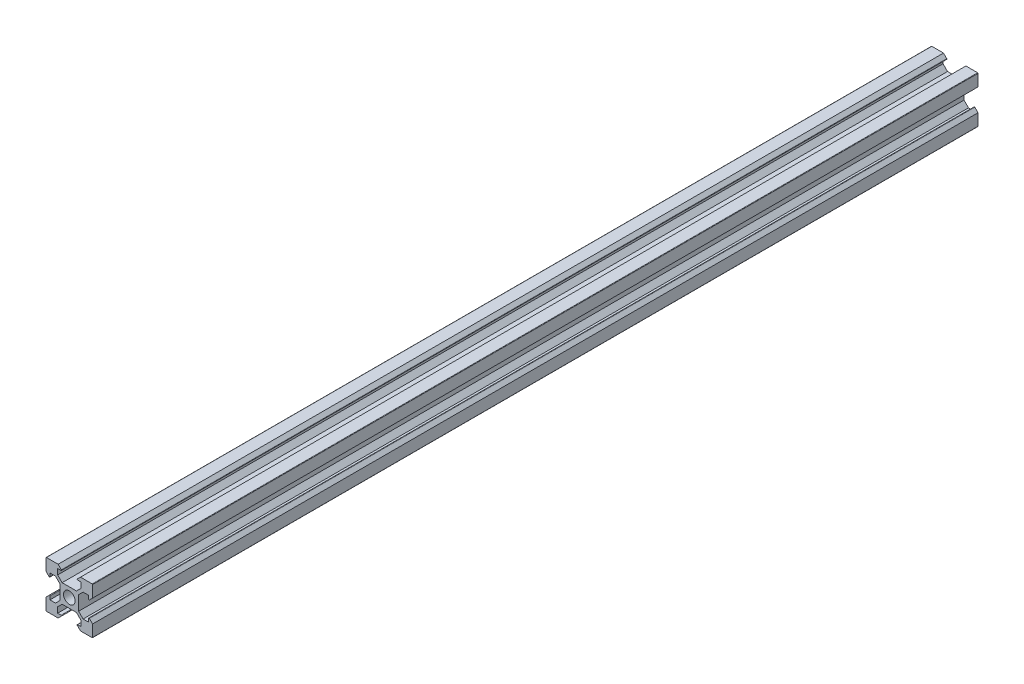
from build123d import *

# Parameters (mm, degrees)
SKETCH1_R           = 2.5
BOSS_EXTRUDE4_DEPTH = 380


with BuildPart() as part:
    # Sketch1 → Boss-Extrude4 (new body)
    with BuildSketch(Plane.XY):
        with BuildLine():
            Line((-10, 9.810918806), (-10, 4.8))
            Line((-10, 4.8), (-8.622781789, 3.422781789))
            ThreePointArc((-8.622781789, 3.422781789), (-8.416722954, 3.381794139), (-8.3, 3.556482384))
            Line((-8.3, 3.556482384), (-8.3, 5))
            Line((-8.3, 5), (-5.919238816, 5))
            Line((-5.919238816, 5), (-4, 3.080761184))
            Line((-4, 3.080761184), (-4, -3.080761184))
            Line((-4, -3.080761184), (-5.919238816, -5))
            Line((-5.919238816, -5), (-8.3, -5))
            Line((-8.3, -5), (-8.3, -3.556482384))
            ThreePointArc((-8.3, -3.556482384), (-8.416722954, -3.381794139), (-8.622781789, -3.422781789))
            Line((-8.622781789, -3.422781789), (-10, -4.8))
            Line((-10, -4.8), (-10, -9.810918806))
            ThreePointArc((-10, -9.810918806), (-9.9446194, -9.9446194), (-9.810918806, -10))
            Line((-9.810918806, -10), (-4.8, -10))
            Line((-4.8, -10), (-3.422781789, -8.622781789))
            ThreePointArc((-3.422781789, -8.622781789), (-3.381794139, -8.416722954), (-3.556482384, -8.3))
            Line((-3.556482384, -8.3), (-5, -8.3))
            Line((-5, -8.3), (-5, -5.919238816))
            Line((-5, -5.919238816), (-3.080761184, -4))
            Line((-3.080761184, -4), (0, -4))
            Line((0, -4), (3.080761184, -4))
            Line((3.080761184, -4), (5, -5.919238816))
            Line((5, -5.919238816), (5, -8.3))
            Line((5, -8.3), (3.556482384, -8.3))
            ThreePointArc((3.556482384, -8.3), (3.381794139, -8.416722954), (3.422781789, -8.622781789))
            Line((3.422781789, -8.622781789), (4.8, -10))
            Line((4.8, -10), (9.810918806, -10))
            ThreePointArc((9.810918806, -10), (9.9446194, -9.9446194), (10, -9.810918806))
            Line((10, -9.810918806), (10, -4.8))
            Line((10, -4.8), (8.622781789, -3.422781789))
            ThreePointArc((8.622781789, -3.422781789), (8.416722954, -3.381794139), (8.3, -3.556482384))
            Line((8.3, -3.556482384), (8.3, -5))
            Line((8.3, -5), (5.919238816, -5))
            Line((5.919238816, -5), (4, -3.080761184))
            Line((4, -3.080761184), (4, 3.080761184))
            Line((4, 3.080761184), (5.919238816, 5))
            Line((5.919238816, 5), (8.3, 5))
            Line((8.3, 5), (8.3, 3.556482384))
            ThreePointArc((8.3, 3.556482384), (8.416722954, 3.381794139), (8.622781789, 3.422781789))
            Line((8.622781789, 3.422781789), (10, 4.8))
            Line((10, 4.8), (10, 9.810918806))
            ThreePointArc((10, 9.810918806), (9.9446194, 9.9446194), (9.810918806, 10))
            Line((9.810918806, 10), (4.8, 10))
            Line((4.8, 10), (3.422781789, 8.622781789))
            ThreePointArc((3.422781789, 8.622781789), (3.381794139, 8.416722954), (3.556482384, 8.3))
            Line((3.556482384, 8.3), (5, 8.3))
            Line((5, 8.3), (5, 5.919238816))
            Line((5, 5.919238816), (3.080761184, 4))
            Line((3.080761184, 4), (-3.080761184, 4))
            Line((-3.080761184, 4), (-5, 5.919238816))
            Line((-5, 5.919238816), (-5, 8.3))
            Line((-5, 8.3), (-3.556482384, 8.3))
            ThreePointArc((-3.556482384, 8.3), (-3.381794139, 8.416722954), (-3.422781789, 8.622781789))
            Line((-3.422781789, 8.622781789), (-4.8, 10))
            Line((-4.8, 10), (-9.810918806, 10))
            ThreePointArc((-9.810918806, 10), (-9.9446194, 9.9446194), (-10, 9.810918806))
        make_face()
        Circle(SKETCH1_R, mode=Mode.SUBTRACT)
    extrude(amount=BOSS_EXTRUDE4_DEPTH)


solid = part.part
